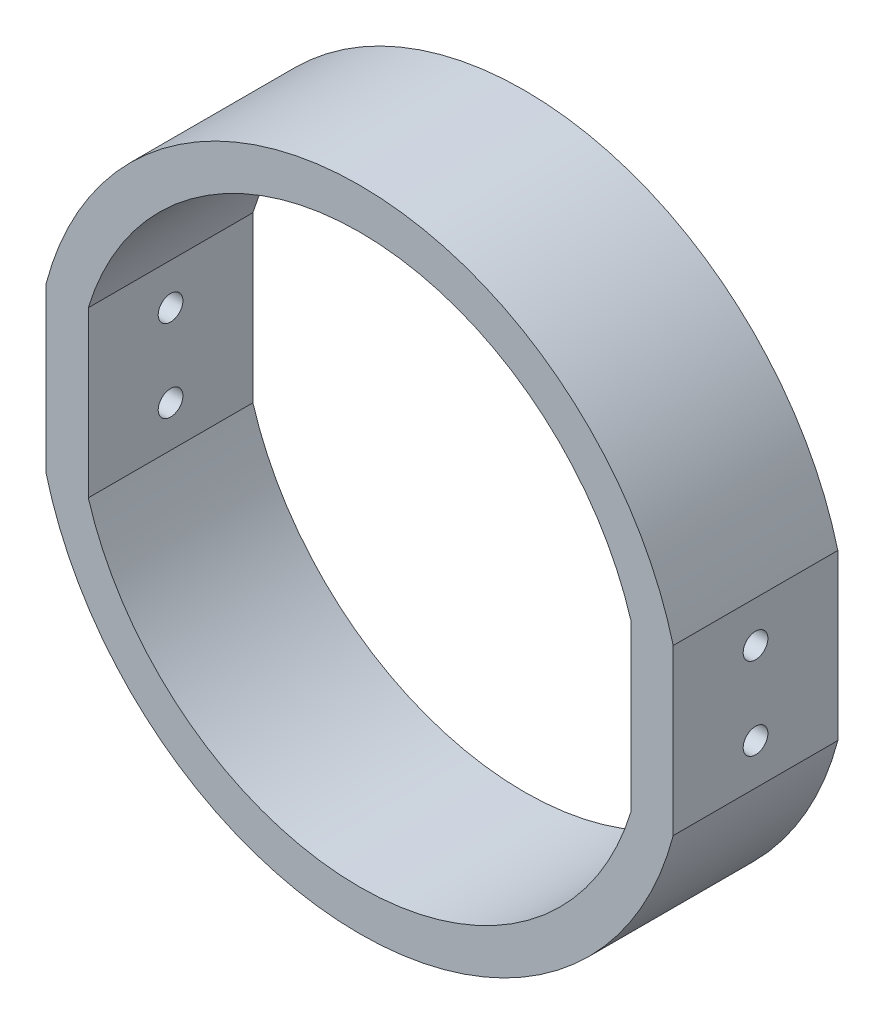
from build123d import *

# Parameters (mm, degrees)
BOSS_EXTRUDE1_DEPTH = 20
SKETCH3_R           = 1.5
CUT_EXTRUDE2_DEPTH  = 77.182012842


with BuildPart() as part:
    # Sketch1 → Boss-Extrude1 (new body)
    with BuildSketch(Plane.XY):
        with BuildLine():
            Line((38.091006421, 10), (38.091006421, -10))
            ThreePointArc((38.091006421, -10), (0, -39.381782212), (-38.091006421, -10))
            Line((-38.091006421, -10), (-38.091006421, 10))
            ThreePointArc((-38.091006421, 10), (0, 39.381782212), (38.091006421, 10))
        make_face()
        with BuildLine():
            Line((-32.976154675, 10), (-32.976154675, -10))
            ThreePointArc((-32.976154675, -10), (0, -34.459059435), (32.976154675, -10))
            Line((32.976154675, -10), (32.976154675, 10))
            ThreePointArc((32.976154675, 10), (0, 34.459059435), (-32.976154675, 10))
        make_face(mode=Mode.SUBTRACT)
    extrude(amount=BOSS_EXTRUDE1_DEPTH)

    # Sketch3 → Cut-Extrude2 (cut, through all)
    with BuildSketch(Plane(origin=(38.091006421, 0, 0), x_dir=(0, 0, -1), z_dir=(1, 0, 0))):
        with Locations((-10, 5)):
            Circle(SKETCH3_R)
        with Locations((-10, -5)):
            Circle(SKETCH3_R)
    extrude(amount=-CUT_EXTRUDE2_DEPTH, mode=Mode.SUBTRACT)


solid = part.part
